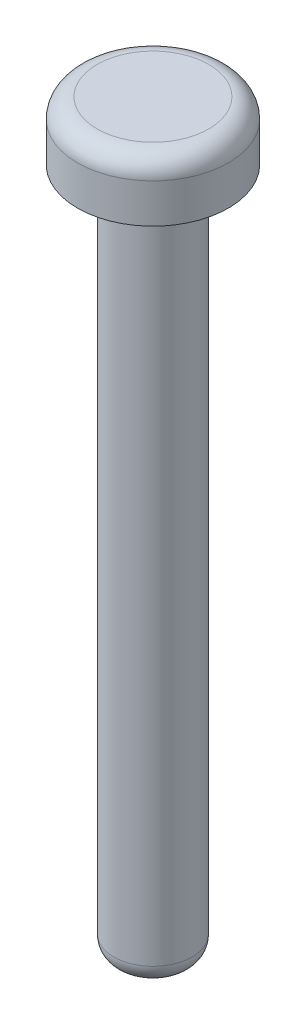
from build123d import *

# Parameters (mm, degrees)
SKETCH1_R           = 2
BOSS_EXTRUDE1_DEPTH = 35
SKETCH2_R           = 3.85
BOSS_EXTRUDE2_DEPTH = 3
FILLET1_R           = 1
FILLET2_R           = 1


with BuildPart() as part:
    # Sketch1 → Boss-Extrude1 (new body)
    with BuildSketch(Plane(origin=(0, 0, 0), x_dir=(1, 0, 0), z_dir=(0, 1, 0))):
        Circle(SKETCH1_R)
    extrude(amount=BOSS_EXTRUDE1_DEPTH)

    # Sketch2 → Boss-Extrude2 (add)
    with BuildSketch(Plane(origin=(0, 35, 0), x_dir=(1, 0, 0), z_dir=(0, 1, 0))):
        Circle(SKETCH2_R)
    extrude(amount=BOSS_EXTRUDE2_DEPTH)

    # Fillet1
    fillet1_edges = [part.edges().sort_by_distance(p)[0] for p in [
        (-3.85, 38, 0),
    ]]
    fillet(fillet1_edges, radius=FILLET1_R)

    # Fillet2
    fillet2_edges = [part.edges().sort_by_distance(p)[0] for p in [
        (-2, 0, 0),
        (-2, 35, 0),
    ]]
    fillet(fillet2_edges, radius=FILLET2_R)


solid = part.part
